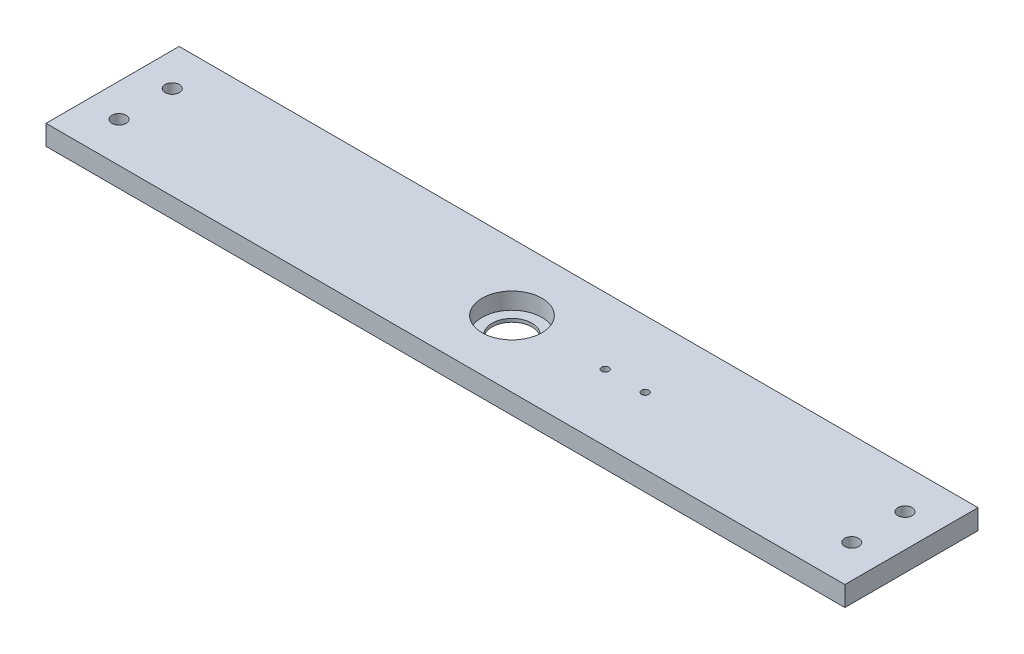
from build123d import *

# Parameters (mm, degrees)
SKETCH1_W               = 381
SKETCH1_H               = 63.5
BOSS_EXTRUDE1_DEPTH     = 9.525
SKETCH2_R               = 14.2875
CUT_EXTRUDE1_DEPTH      = 7.9375
F_1_4_CLEARANCE_HOLE1_D = 6.7564
F_8_32_TAPPED_HOLE1_D   = 3.4544
SKETCH8_R               = 9.525
CUT_EXTRUDE2_DEPTH      = 2.5875


with BuildPart() as part:
    # Sketch1 → Boss-Extrude1 (new body)
    with BuildSketch(Plane(origin=(0, 0, 0), x_dir=(1, 0, 0), z_dir=(0, 1, 0))):
        Rectangle(SKETCH1_W, SKETCH1_H)
    extrude(amount=BOSS_EXTRUDE1_DEPTH)

    # Sketch2 → Cut-Extrude1 (cut)
    with BuildSketch(Plane(origin=(0, 9.525, 0), x_dir=(1, 0, 0), z_dir=(0, 1, 0))):
        with Locations(Location((0, 0, 0), (0, 0, 270))):  # turned: the seam where the file's is
            Circle(SKETCH2_R)
    extrude(amount=-CUT_EXTRUDE1_DEPTH, mode=Mode.SUBTRACT)

    # 1/4 Clearance Hole1 (through all)
    with Locations(Plane(origin=(0, 9.525, 0), x_dir=(1, 0, 0), z_dir=(0, 1, 0))):
        with Locations((-174.738781322, 12.7), (174.738781322, 12.7), (-174.738781322, -12.7), (174.738781322, -12.7)):
            Hole(F_1_4_CLEARANCE_HOLE1_D / 2)

    # #8-32 Tapped Hole1 (through all)
    with Locations(Plane(origin=(0, 9.525, 0), x_dir=(1, 0, 0), z_dir=(0, 1, 0))):
        with Locations((63.5, 0), (44.45, 0)):
            Hole(F_8_32_TAPPED_HOLE1_D / 2)

    # Sketch8 → Cut-Extrude2 (cut, through all)
    with BuildSketch(Plane(origin=(0, 1.5875, 0), x_dir=(1, 0, 0), z_dir=(0, 1, 0))):
        with Locations(Location((0, 0, 0), (0, 0, 270))):  # turned: the seam where the file's is
            Circle(SKETCH8_R)
    extrude(amount=-CUT_EXTRUDE2_DEPTH, mode=Mode.SUBTRACT)


solid = part.part
